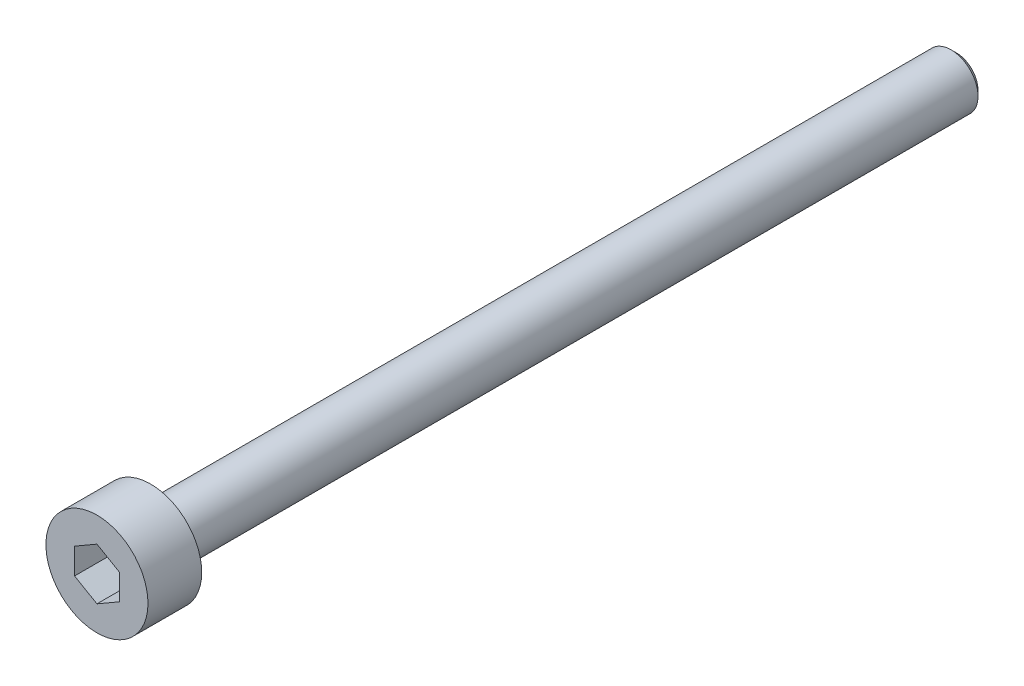
from build123d import *

# Parameters (mm, degrees)
SKETCH1_R           = 2.85
BOSS_EXTRUDE1_DEPTH = 3
SKETCH2_R           = 1.5
BOSS_EXTRUDE2_DEPTH = 45
CHAMFER1_SIZE       = 0.3
CUT_EXTRUDE1_DEPTH  = 2


with BuildPart() as part:
    # Sketch1 → Boss-Extrude1 (new body)
    with BuildSketch(Plane.XY):
        Circle(SKETCH1_R)
    extrude(amount=BOSS_EXTRUDE1_DEPTH)

    # Sketch2 → Boss-Extrude2 (add)
    with BuildSketch(Plane(origin=(0, 0, 0), x_dir=(-1, 0, 0), z_dir=(0, 0, -1))):
        Circle(SKETCH2_R)
    extrude(amount=BOSS_EXTRUDE2_DEPTH)

    # Chamfer1
    chamfer1_edges = [part.edges().sort_by_distance(p)[0] for p in [
        (1.5, 0, -45),
    ]]
    chamfer(chamfer1_edges, length=CHAMFER1_SIZE)

    # Sketch3 → Cut-Extrude1 (cut)
    with BuildSketch(Plane.XY.offset(3)):
        Polygon((0, 1.443375673), (-1.25, 0.721687836), (-1.25, -0.721687836), (0, -1.443375673), (1.25, -0.721687836), (1.25, 0.721687836), align=None)
    extrude(amount=-CUT_EXTRUDE1_DEPTH, mode=Mode.SUBTRACT)


solid = part.part
